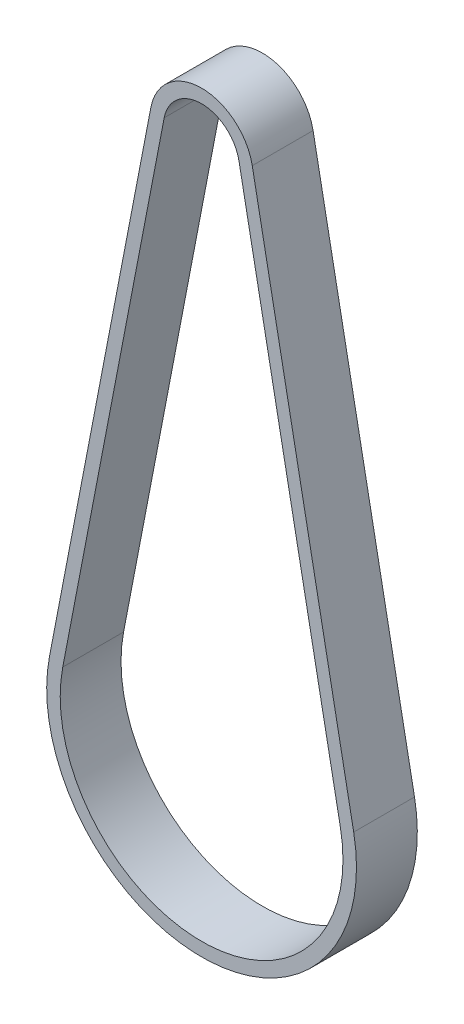
from build123d import *

# Parameters (mm, degrees)
EXTRUDE_THIN1_DEPTH = 4.5


with BuildPart() as part:
    # Sketch1 → Extrude-Thin1 (new body, symmetric)
    with BuildSketch(Plane.XY):
        with BuildLine():
            Line((22.506057662, -76.453668771), (7.497109522, 1.444497772))
            ThreePointArc((7.497109522, 1.444497772), (0, 7.635), (-7.497109522, 1.444497772))
            Line((-7.497109522, 1.444497772), (-22.506057662, -76.453668771))
            ThreePointArc((-22.506057662, -76.453668771), (0, -103.71), (22.506057662, -76.453668771))
        make_face()
        with BuildLine():
            Line((20.542178285, -76.832057185), (5.533230145, 1.066109358))
            ThreePointArc((5.533230145, 1.066109358), (0, 5.635), (-5.533230145, 1.066109358))
            Line((-5.533230145, 1.066109358), (-20.542178285, -76.832057185))
            ThreePointArc((-20.542178285, -76.832057185), (0, -101.71), (20.542178285, -76.832057185))
        make_face(mode=Mode.SUBTRACT)
    extrude(amount=EXTRUDE_THIN1_DEPTH, both=True)


solid = part.part
